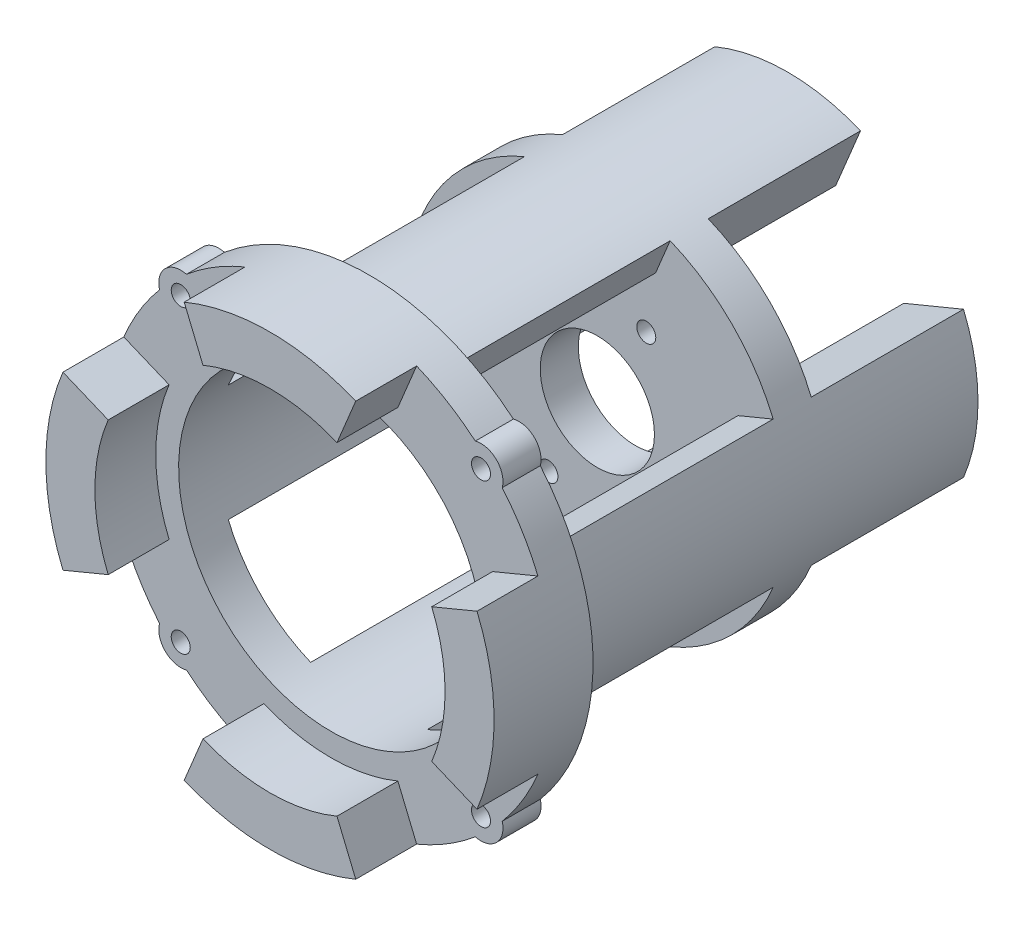
from build123d import *

# Parameters (mm, degrees)
SKETCH1_R           = 25
SKETCH1_R_2         = 1.25
SKETCH1_R_3         = 7.5
BOSS_EXTRUDE1_DEPTH = 5
BOSS_EXTRUDE2_DEPTH = 20
BOSS_EXTRUDE3_DEPTH = 30
SKETCH4_R           = 1.25
SKETCH4_R_2         = 20
BOSS_EXTRUDE4_DEPTH = 5
BOSS_EXTRUDE5_DEPTH = 8


with BuildPart() as part:
    # Sketch1 → Boss-Extrude1 (new body)
    with BuildSketch(Plane.XY):
        Circle(SKETCH1_R)
        with Locations((-12.85, 0)):
            Circle(SKETCH1_R_2, mode=Mode.SUBTRACT)
        with Locations((-6.425, 11.128426439)):
            Circle(SKETCH1_R_2, mode=Mode.SUBTRACT)
        with Locations((6.425, 11.128426439)):
            Circle(SKETCH1_R_2, mode=Mode.SUBTRACT)
        with Locations((12.85, 0)):
            Circle(SKETCH1_R_2, mode=Mode.SUBTRACT)
        with Locations((6.425, -11.128426439)):
            Circle(SKETCH1_R_2, mode=Mode.SUBTRACT)
        with Locations((-6.425, -11.128426439)):
            Circle(SKETCH1_R_2, mode=Mode.SUBTRACT)
        Circle(SKETCH1_R_3, mode=Mode.SUBTRACT)
    extrude(amount=BOSS_EXTRUDE1_DEPTH)

    # Sketch2 → Boss-Extrude2 (add)
    with BuildSketch(Plane(origin=(0, 0, 0), x_dir=(-1, 0, 0), z_dir=(0, 0, -1))):
        with BuildLine():
            Line((-15.244012286, 6.314276634), (-23.096988313, 9.567085809))
            ThreePointArc((-23.096988313, 9.567085809), (-25, 0), (-23.096988313, -9.567085809))
            Line((-23.096988313, -9.567085809), (-15.244012286, -6.314276634))
            ThreePointArc((-15.244012286, -6.314276634), (-16.5, 0), (-15.244012286, 6.314276634))
        make_face()
        with BuildLine():
            Line((6.314276634, 15.244012286), (9.567085809, 23.096988313))
            ThreePointArc((9.567085809, 23.096988313), (0, 25), (-9.567085809, 23.096988313))
            Line((-9.567085809, 23.096988313), (-6.314276634, 15.244012286))
            ThreePointArc((-6.314276634, 15.244012286), (0, 16.5), (6.314276634, 15.244012286))
        make_face()
        with BuildLine():
            ThreePointArc((25, 0), (24.51963201, 4.87725805), (23.096988313, 9.567085809))
            Line((23.096988313, 9.567085809), (15.244012286, 6.314276634))
            ThreePointArc((15.244012286, 6.314276634), (16.5, 0), (15.244012286, -6.314276634))
            Line((15.244012286, -6.314276634), (23.096988313, -9.567085809))
            ThreePointArc((23.096988313, -9.567085809), (24.51963201, -4.87725805), (25, 0))
        make_face()
        with BuildLine():
            ThreePointArc((-9.567085809, -23.096988313), (0, -25), (9.567085809, -23.096988313))
            Line((9.567085809, -23.096988313), (6.314276634, -15.244012286))
            ThreePointArc((6.314276634, -15.244012286), (0, -16.5), (-6.314276634, -15.244012286))
            Line((-6.314276634, -15.244012286), (-9.567085809, -23.096988313))
        make_face()
    extrude(amount=BOSS_EXTRUDE2_DEPTH)

    # Sketch3 → Boss-Extrude3 (add)
    with BuildSketch(Plane.XY.offset(5)):
        with BuildLine():
            Line((7.653668647, 18.47759065), (9.567085809, 23.096988313))
            ThreePointArc((9.567085809, 23.096988313), (0, 25), (-9.567085809, 23.096988313))
            Line((-9.567085809, 23.096988313), (-7.653668647, 18.47759065))
            ThreePointArc((-7.653668647, 18.47759065), (0, 20), (7.653668647, 18.47759065))
        make_face()
        with BuildLine():
            ThreePointArc((25, 0), (24.51963201, 4.87725805), (23.096988313, 9.567085809))
            Line((23.096988313, 9.567085809), (18.47759065, 7.653668647))
            ThreePointArc((18.47759065, 7.653668647), (20, 0), (18.47759065, -7.653668647))
            Line((18.47759065, -7.653668647), (23.096988313, -9.567085809))
            ThreePointArc((23.096988313, -9.567085809), (24.51963201, -4.87725805), (25, 0))
        make_face()
        with BuildLine():
            Line((-7.653668647, -18.47759065), (-9.567085809, -23.096988313))
            ThreePointArc((-9.567085809, -23.096988313), (0, -25), (9.567085809, -23.096988313))
            Line((9.567085809, -23.096988313), (7.653668647, -18.47759065))
            ThreePointArc((7.653668647, -18.47759065), (0, -20), (-7.653668647, -18.47759065))
        make_face()
        with BuildLine():
            Line((-18.47759065, 7.653668647), (-23.096988313, 9.567085809))
            ThreePointArc((-23.096988313, 9.567085809), (-25, 0), (-23.096988313, -9.567085809))
            Line((-23.096988313, -9.567085809), (-18.47759065, -7.653668647))
            ThreePointArc((-18.47759065, -7.653668647), (-20, 0), (-18.47759065, 7.653668647))
        make_face()
    extrude(amount=BOSS_EXTRUDE3_DEPTH)

    # Sketch4 → Boss-Extrude4 (add)
    with BuildSketch(Plane.XY.offset(35)):
        with BuildLine():
            ThreePointArc((22.507298661, 18.971764755), (21.760152434, 21.760152434), (18.971764755, 22.507298661))
            ThreePointArc((18.971764755, 22.507298661), (0, 29.436479935), (-18.971764755, 22.507298661))
            ThreePointArc((-18.971764755, 22.507298661), (-21.760152434, 21.760152434), (-22.507298661, 18.971764755))
            ThreePointArc((-22.507298661, 18.971764755), (-29.436479935, 0), (-22.507298661, -18.971764755))
            ThreePointArc((-22.507298661, -18.971764755), (-21.760152434, -21.760152434), (-18.971764755, -22.507298661))
            ThreePointArc((-18.971764755, -22.507298661), (0, -29.436479935), (18.971764755, -22.507298661))
            ThreePointArc((18.971764755, -22.507298661), (21.760152434, -21.760152434), (22.507298661, -18.971764755))
            ThreePointArc((22.507298661, -18.971764755), (29.436479935, 0), (22.507298661, 18.971764755))
        make_face()
        with Locations((-19.718910982, -19.718910982)):
            Circle(SKETCH4_R, mode=Mode.SUBTRACT)
        with Locations((19.718910982, -19.718910982)):
            Circle(SKETCH4_R, mode=Mode.SUBTRACT)
        with Locations((-19.718910982, 19.718910982)):
            Circle(SKETCH4_R, mode=Mode.SUBTRACT)
        Circle(SKETCH4_R_2, mode=Mode.SUBTRACT)
        with Locations((19.718910982, 19.718910982)):
            Circle(SKETCH4_R, mode=Mode.SUBTRACT)
    extrude(amount=BOSS_EXTRUDE4_DEPTH)

    # Sketch5 → Boss-Extrude5 (add)
    with BuildSketch(Plane.XY.offset(40)):
        with BuildLine():
            ThreePointArc((11.264853178, 27.195761321), (0, 29.436479935), (-11.264853178, 27.195761321))
            Line((-11.264853178, 27.195761321), (-8.801718944, 21.249229248))
            ThreePointArc((-8.801718944, 21.249229248), (0, 23), (8.801718944, 21.249229248))
            Line((8.801718944, 21.249229248), (11.264853178, 27.195761321))
        make_face()
        with BuildLine():
            Line((21.249229248, -8.801718944), (27.195761321, -11.264853178))
            ThreePointArc((27.195761321, -11.264853178), (29.436479935, 0), (27.195761321, 11.264853178))
            Line((27.195761321, 11.264853178), (21.249229248, 8.801718944))
            ThreePointArc((21.249229248, 8.801718944), (23, 0), (21.249229248, -8.801718944))
        make_face()
        with BuildLine():
            Line((-8.801718944, -21.249229248), (-11.264853178, -27.195761321))
            ThreePointArc((-11.264853178, -27.195761321), (0, -29.436479935), (11.264853178, -27.195761321))
            Line((11.264853178, -27.195761321), (8.801718944, -21.249229248))
            ThreePointArc((8.801718944, -21.249229248), (0, -23), (-8.801718944, -21.249229248))
        make_face()
        with BuildLine():
            Line((-21.249229248, 8.801718944), (-27.195761321, 11.264853178))
            ThreePointArc((-27.195761321, 11.264853178), (-29.436479935, 0), (-27.195761321, -11.264853178))
            Line((-27.195761321, -11.264853178), (-21.249229248, -8.801718944))
            ThreePointArc((-21.249229248, -8.801718944), (-23, 0), (-21.249229248, 8.801718944))
        make_face()
    extrude(amount=BOSS_EXTRUDE5_DEPTH)


solid = part.part
